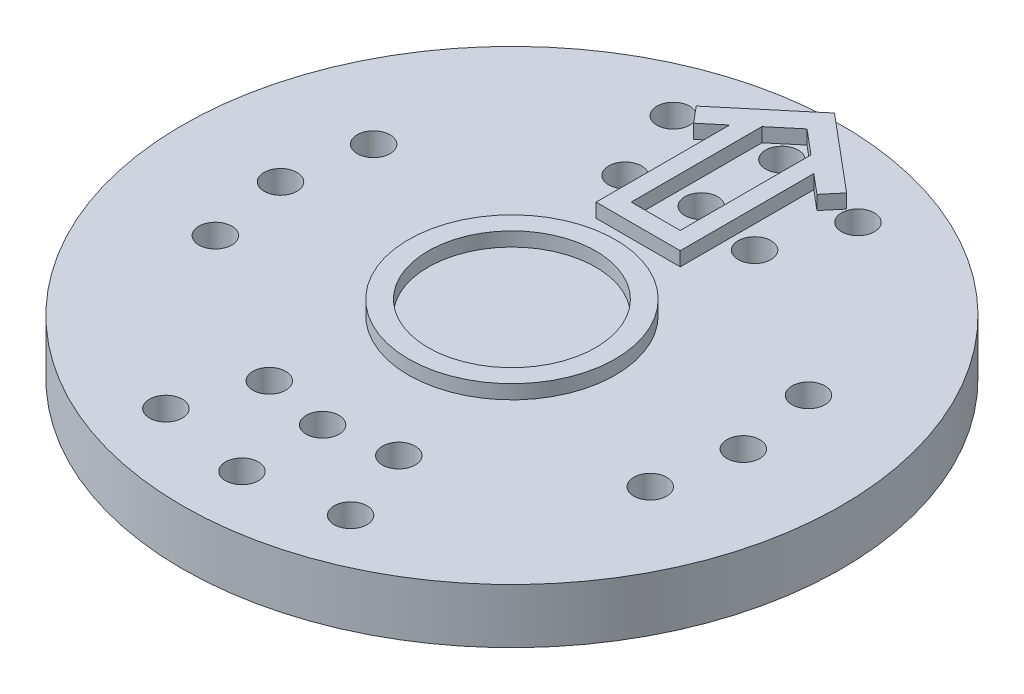
from build123d import *

# Parameters (mm, degrees)
SKETCH1_R                       = 11.938
EXTRUDE1_DEPTH                  = 1.9812
SKETCH2_R                       = 4.445
EXTRUDE2_DEPTH                  = 2.286
F_3_64_0_04688_DIAMETER_HOLE1_D = 1.190752
CIRPATTERN1_COUNT               = 2
SKETCH6_R                       = 3.7465
SKETCH6_R_2                     = 3.0353
EXTRUDE4_DEPTH                  = 0.508
EXTRUDE3_DEPTH                  = 0.508


with BuildPart() as part:
    # Sketch1 → Extrude1 (new body)
    with BuildSketch(Plane(origin=(0, 0, 0), x_dir=(1, 0, 0), z_dir=(0, 1, 0))):
        Circle(SKETCH1_R)
    extrude(amount=-EXTRUDE1_DEPTH)

    # Sketch2 → Extrude2 (add)
    with BuildSketch(Plane.XZ.offset(1.9812)):
        Circle(SKETCH2_R)
    extrude(amount=EXTRUDE2_DEPTH)

    # 3/64 (0.04688) Diameter Hole1 (through all)
    with Locations(Plane(origin=(0, 0, -6.858), x_dir=(0, 0, 1), z_dir=(0, 1, 0))):
        with Locations((0, 0), (0.413588007, -2.345574143), (0.413588007, 2.345574143), (-2.331254139, 3.344614982), (-2.921, 0), (-2.331254139, -3.344614982), (3.991187159, -7.876503547), (6.858, -8.382), (9.724812841, -7.876503547)):
            f_3_64_0_04688_diameter_hole1 = Hole(F_3_64_0_04688_DIAMETER_HOLE1_D / 2)

    # CirPattern1: 3/64 (0.04688) Diameter Hole1 ×2 about axis
    cirpattern1_axis = Axis((0, 0, 0), (0, 1, 0))
    for i in range(1, CIRPATTERN1_COUNT):
        add(f_3_64_0_04688_diameter_hole1.rotate(cirpattern1_axis, i * 360 / CIRPATTERN1_COUNT), mode=Mode.SUBTRACT)

    # Sketch6 → Extrude4 (add)
    with BuildSketch(Plane(origin=(0, 0, 0), x_dir=(1, 0, 0), z_dir=(0, 1, 0))):
        Circle(SKETCH6_R)
        Circle(SKETCH6_R_2, mode=Mode.SUBTRACT)
    extrude(amount=EXTRUDE4_DEPTH)

    # Sketch5 → Extrude3 (add)
    with BuildSketch(Plane(origin=(0, 0, 0), x_dir=(1, 0, 0), z_dir=(0, 1, 0))):
        Polygon((-2.72405404, 9.39824726), (0, 11.684), (2.72405404, 9.39824726), (2.234249881, 8.814521394), (1.524, 9.410491808), (1.524, 4.572), (-1.524, 4.572), (-1.524, 9.410491808), (-2.234249881, 8.814521394), align=None)
        Polygon((0, 10.689279646), (-0.889, 9.943320073), (-0.889, 5.207), (0.889, 5.207), (0.889, 9.943320073), align=None, mode=Mode.SUBTRACT)
    extrude(amount=EXTRUDE3_DEPTH)


solid = part.part
